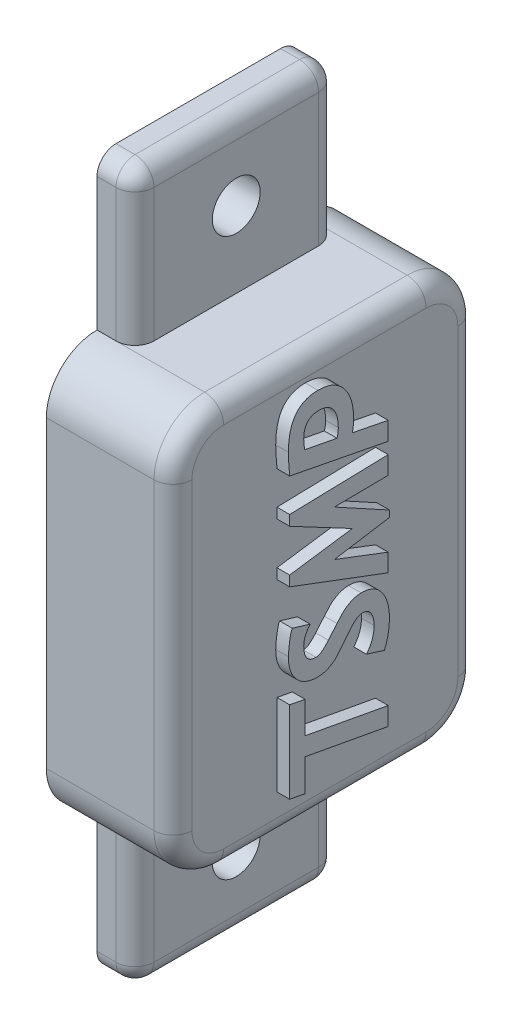
from build123d import *

# Parameters (mm, degrees)
BOSS_EXTRUDE1_DEPTH      = 6.35
SHELL1_T                 = -1.27
SKETCH2_W                = 3.81
SKETCH2_H                = 20.32
BOSS_EXTRUDE2_DEPTH      = 15.24
M4_CLEARANCE_HOLE1_D     = 4.8
M4_CLEARANCE_HOLE1_DEPTH = 3.81
BOSS_EXTRUDE3_DEPTH      = 1.27
FILLET1_R                = 1.905


with BuildPart() as part:
    # Sketch1 → Boss-Extrude1 (new body, symmetric)
    with BuildSketch(Plane(origin=(0, 0, 0), x_dir=(0, 0, -1), z_dir=(1, 0, 0))):
        with BuildLine():
            Line((10.16, 20.32), (-10.16, 20.32))
            ThreePointArc((-10.16, 20.32), (-13.752102448, 18.832102448), (-15.24, 15.24))
            Line((-15.24, 15.24), (-15.24, -15.24))
            ThreePointArc((-15.24, -15.24), (-13.752102448, -18.832102448), (-10.16, -20.32))
            Line((-10.16, -20.32), (10.16, -20.32))
            ThreePointArc((10.16, -20.32), (13.752102448, -18.832102448), (15.24, -15.24))
            Line((15.24, -15.24), (15.24, 15.24))
            ThreePointArc((15.24, 15.24), (13.752102448, 18.832102448), (10.16, 20.32))
        make_face()
    extrude(amount=BOSS_EXTRUDE1_DEPTH, both=True)

    # Shell1
    shell1_openings = [part.faces().sort_by_distance(p)[0] for p in [
        (-6.35, 0, 0),
    ]]
    offset(amount=SHELL1_T, openings=shell1_openings, kind=Kind.INTERSECTION)

    # Sketch2 → Boss-Extrude2 (add)
    with BuildSketch(Plane.XZ.offset(20.32)):
        with Locations((-4.445, 0)):
            Rectangle(SKETCH2_W, SKETCH2_H)
    boss_extrude2 = extrude(amount=BOSS_EXTRUDE2_DEPTH)

    # M4 Clearance Hole1
    with Locations(Plane(origin=(-2.54, 0, 0), x_dir=(0, 0, -1), z_dir=(1, 0, 0))):
        with Locations((0, -27.94)):
            m4_clearance_hole1 = Hole(M4_CLEARANCE_HOLE1_D / 2, depth=M4_CLEARANCE_HOLE1_DEPTH)

    # Mirror1: Boss-Extrude2, M4 Clearance Hole1 across plane
    add(boss_extrude2.mirror(Plane.ZX))
    add(m4_clearance_hole1.mirror(Plane.ZX), mode=Mode.SUBTRACT)

    # Sketch8 → Boss-Extrude3 (add)
    with BuildSketch(Plane(origin=(6.35, 0, 0), x_dir=(0, 0, -1), z_dir=(1, 0, 0))):
        Polygon((-3.263618594, -8.225283619), (-3.263618594, -11.400271175), (5.08, -12.938625853), (5.08, -14.761786743), (-3.263618594, -13.221426387), (-3.263618594, -16.430510462), (-4.80397895, -16.14570425), (-4.80397895, -7.934460374), align=None)
        with BuildLine():
            add(Edge.make_bspline(
                [(-2.750165142, -1.95352993), (-2.80125104, -2.017677687), (-2.900986105, -2.142913435), (-3.031358515, -2.338261172), (-3.143006892, -2.533506612), (-3.233848259, -2.730752845), (-3.303890362, -2.928950045), (-3.354883675, -3.127492488), (-3.386187219, -3.327085952), (-3.39005041, -3.461020967), (-3.391981957, -3.527986804)],
                knots=[0, 0, 0, 0, 0.000245923, 0.000480115, 0.000703764, 0.000920052, 0.001130657, 0.001333509, 0.001534337, 0.001735155, 0.001735155, 0.001735155, 0.001735155], degree=3))
            add(Edge.make_bspline(
                [(-3.391981957, -3.527986804), (-3.3916293, -3.592878461), (-3.390944594, -3.718869665), (-3.373803164, -3.900934818), (-3.349810891, -4.070269357), (-3.319309536, -4.227879526), (-3.274070717, -4.37216332), (-3.222660858, -4.505639649), (-3.160855456, -4.626504675), (-3.087780872, -4.734006273), (-3.005813293, -4.828538209), (-2.913292027, -4.910514792), (-2.811858608, -4.980505864), (-2.699620978, -5.036969834), (-2.579328244, -5.08160209), (-2.448326395, -5.110523489), (-2.308949539, -5.131974126), (-2.212064918, -5.133667989), (-2.162501621, -5.134534519)],
                knots=[0, 0, 0, 0, 0.000194592, 0.000377813, 0.000548, 0.0007077, 0.0008587, 0.001000976, 0.00113643, 0.001264934, 0.001390028, 0.001510786, 0.001634846, 0.001758631, 0.001886806, 0.002018648, 0.002160471, 0.002309013, 0.002309013, 0.002309013, 0.002309013], degree=3))
            add(Edge.make_bspline(
                [(-2.162501621, -5.134534519), (-2.117436706, -5.131528884), (-2.024312956, -5.125317932), (-1.88280649, -5.081657896), (-1.736607088, -5.012195006), (-1.58315581, -4.916720556), (-1.425322977, -4.792915034), (-1.260334105, -4.64296288), (-1.088306144, -4.467290665), (-0.976998716, -4.336338494), (-0.918981542, -4.268081819)],
                knots=[0, 0, 0, 0, 0.000135112, 0.0002792, 0.000440716, 0.000619941, 0.000820127, 0.001041662, 0.00128845, 0.001557128, 0.001557128, 0.001557128, 0.001557128], degree=3))
            Line((-0.918981542, -4.268081819), (-0.054534519, -3.24518627))
            add(Edge.make_bspline(
                [(-0.054534519, -3.24518627), (0.007627221, -3.172308071), (0.122069723, -3.038136097), (0.279085299, -2.854357732), (0.413087131, -2.710696977), (0.521828813, -2.591380531), (0.63069573, -2.492559642), (0.748004134, -2.396766845), (0.884686606, -2.300051516), (1.086844297, -2.168430987), (1.353379879, -2.021290492), (1.687687303, -1.892462062), (2.026955675, -1.812767653), (2.256261402, -1.80229614), (2.370329635, -1.797087082)],
                knots=[0, 0, 0, 0, 0.000287379, 0.000529078, 0.000724978, 0.000876789, 0.001013057, 0.001165607, 0.001330914, 0.001515054, 0.0018893, 0.002241666, 0.002587132, 0.002929093, 0.002929093, 0.002929093, 0.002929093], degree=3))
            add(Edge.make_bspline(
                [(2.370329635, -1.797087082), (2.478836795, -1.799964201), (2.69094982, -1.805588481), (2.998846952, -1.855418306), (3.28972316, -1.932701452), (3.560883137, -2.045837123), (3.814753113, -2.189996227), (4.050631053, -2.364961838), (4.266669818, -2.574066327), (4.461480384, -2.813118763), (4.638288906, -3.075229865), (4.789881922, -3.359679973), (4.921682336, -3.660747475), (5.025154706, -3.982411783), (5.10687616, -4.321730324), (5.16790922, -4.680057446), (5.201067337, -5.057685433), (5.205896626, -5.315653535), (5.208363363, -5.447420217)],
                knots=[0, 0, 0, 0, 0.000325316, 0.000635937, 0.000933224, 0.001226362, 0.001514691, 0.001807122, 0.002105004, 0.002414197, 0.002730719, 0.003051985, 0.003379869, 0.003715393, 0.004064185, 0.00442623, 0.004804836, 0.005200138, 0.005200138, 0.005200138, 0.005200138], degree=3))
            add(Edge.make_bspline(
                [(5.208363363, -5.447420217), (5.206855206, -5.557777808), (5.203862691, -5.776751431), (5.178842454, -6.102740636), (5.139239727, -6.423452807), (5.082416071, -6.739992962), (5.010856006, -7.052140548), (4.921802425, -7.359874574), (4.818672032, -7.663007591), (4.736163682, -7.860022177), (4.694909911, -7.958528505)],
                knots=[0, 0, 0, 0, 0.000331034, 0.000656844, 0.00098025, 0.00130011, 0.001621219, 0.001940525, 0.002260837, 0.002581143, 0.002581143, 0.002581143, 0.002581143], degree=3))
            Line((4.694909911, -7.958528505), (2.897822829, -7.388916082))
            add(Edge.make_bspline(
                [(2.897822829, -7.388916082), (2.959364284, -7.312381552), (3.080897423, -7.161239828), (3.237818498, -6.91868989), (3.370486213, -6.66757251), (3.479726078, -6.407287772), (3.564256024, -6.137321737), (3.623924089, -5.858006554), (3.661279945, -5.570110201), (3.665746681, -5.37532925), (3.668003007, -5.276937625)],
                knots=[0, 0, 0, 0, 0.000294473, 0.00058153, 0.000865041, 0.001145528, 0.001427181, 0.001712389, 0.002001464, 0.002296544, 0.002296544, 0.002296544, 0.002296544], degree=3))
            add(Edge.make_bspline(
                [(3.668003007, -5.276937625), (3.663994722, -5.161083602), (3.656274846, -4.937951143), (3.601877118, -4.617508863), (3.501824564, -4.329519036), (3.389585851, -4.113482056), (3.282231782, -3.960506275), (3.191956208, -3.862792545), (3.095092781, -3.778818092), (2.988821213, -3.711558275), (2.874408538, -3.660154277), (2.752264675, -3.620636889), (2.621787845, -3.59925378), (2.532190601, -3.59588574), (2.486658932, -3.594174164)],
                knots=[0, 0, 0, 0, 0.000347561, 0.000669396, 0.000970682, 0.001258677, 0.001396705, 0.001530139, 0.001656751, 0.001780275, 0.00190593, 0.002032161, 0.002164383, 0.002301005, 0.002301005, 0.002301005, 0.002301005], degree=3))
            add(Edge.make_bspline(
                [(2.486658932, -3.594174164), (2.438951786, -3.597212088), (2.340631421, -3.603472991), (2.1925958, -3.645712179), (2.043176312, -3.716144538), (1.889639511, -3.811584745), (1.733068719, -3.935429567), (1.57348056, -4.087000052), (1.408564625, -4.263212942), (1.303746122, -4.394340407), (1.249155886, -4.462632541)],
                knots=[0, 0, 0, 0, 0.000143094, 0.000294904, 0.00045824, 0.000637465, 0.000836068, 0.001056007, 0.001297256, 0.001559456, 0.001559456, 0.001559456, 0.001559456], degree=3))
            Line((1.249155886, -4.462632541), (0.404765639, -5.527647318))
            add(Edge.make_bspline(
                [(0.404765639, -5.527647318), (0.344161042, -5.602718848), (0.233172899, -5.740200986), (0.078190288, -5.925533002), (-0.0489091, -6.072532992), (-0.157785231, -6.186597947), (-0.260952852, -6.281911519), (-0.375599357, -6.370811159), (-0.507280539, -6.461763927), (-0.702176664, -6.586646654), (-0.963589433, -6.722379395), (-1.291549182, -6.844902551), (-1.631844494, -6.917501274), (-1.861979507, -6.926889471), (-1.977979286, -6.931621601)],
                knots=[0, 0, 0, 0, 0.000289437, 0.00053006, 0.000724776, 0.000872299, 0.001002899, 0.001145739, 0.001307093, 0.001482919, 0.001839952, 0.002188323, 0.002530548, 0.002878364, 0.002878364, 0.002878364, 0.002878364], degree=3))
            add(Edge.make_bspline(
                [(-1.977979286, -6.931621601), (-2.088436006, -6.929053441), (-2.304834699, -6.92402209), (-2.62050583, -6.880880309), (-2.918727289, -6.81204172), (-3.198077668, -6.711302875), (-3.462534406, -6.589054057), (-3.70587649, -6.432018726), (-3.933410594, -6.250176307), (-4.14030324, -6.039987171), (-4.326720414, -5.807190911), (-4.489787292, -5.55609666), (-4.626674869, -5.28691941), (-4.739783954, -5.001105155), (-4.825105438, -4.697029016), (-4.887008478, -4.37639866), (-4.926313289, -4.039074292), (-4.930305531, -3.808223382), (-4.932342313, -3.690446686)],
                knots=[0, 0, 0, 0, 0.000331234, 0.00064893, 0.000953958, 0.001247672, 0.001538357, 0.001826016, 0.002114192, 0.002410605, 0.002708804, 0.003007549, 0.003307148, 0.003613301, 0.003928199, 0.004253107, 0.004592208, 0.004945413, 0.004945413, 0.004945413, 0.004945413], degree=3))
            add(Edge.make_bspline(
                [(-4.932342313, -3.690446686), (-4.930462207, -3.60483434), (-4.926447217, -3.422008045), (-4.902699038, -3.131017922), (-4.866182337, -2.806698164), (-4.818831787, -2.463228834), (-4.759311523, -2.132128916), (-4.696669399, -1.841035416), (-4.629643785, -1.605349605), (-4.572432677, -1.471089287), (-4.547252224, -1.411996993)],
                knots=[0, 0, 0, 0, 0.000256852, 0.000548511, 0.00087543, 0.001235945, 0.001588454, 0.001884317, 0.002129256, 0.002321811, 0.002321811, 0.002321811, 0.002321811], degree=3))
            Line((-4.547252224, -1.411996993), (-2.750165142, -1.95352993))
        make_face()
        Polygon((5.08, 7.059984964), (-0.311261245, 6.995803283), (5.208363363, 3.979264252), (5.208363363, 3.337447438), (-0.311261245, 2.438903897), (5.08, 0.385090089), (5.08, -1.411996993), (-4.80397895, 2.310540534), (-4.80397895, 3.337447438), (1.485825836, 4.235990978), (-4.80397895, 7.573438416), (-4.80397895, 8.60034532), (5.08, 8.857072046), align=None)
        with BuildLine():
            Line((1.485825836, 12.549524409), (5.08, 11.839514558))
            Line((5.08, 11.839514558), (5.08, 10.012342313))
            Line((5.08, 10.012342313), (-4.80397895, 11.937792757))
            add(Edge.make_bspline(
                [(-4.80397895, 11.937792757), (-4.814156449, 12.051434856), (-4.833847704, 12.271307686), (-4.860016651, 12.59088044), (-4.882078557, 12.889067657), (-4.900309123, 13.166519858), (-4.914485749, 13.423257287), (-4.924511389, 13.659275476), (-4.931022551, 13.874572005), (-4.931917059, 14.010990788), (-4.932342313, 14.075845022)],
                knots=[0, 0, 0, 0, 0.00034229, 0.000662257, 0.000961916, 0.001239287, 0.001496398, 0.00173328, 0.001947972, 0.002142533, 0.002142533, 0.002142533, 0.002142533], degree=3))
            add(Edge.make_bspline(
                [(-4.932342313, 14.075845022), (-4.929994019, 14.233018019), (-4.925441487, 14.537722257), (-4.89155068, 14.979844931), (-4.834371192, 15.392089824), (-4.752611172, 15.773582457), (-4.648650738, 16.124611989), (-4.522356955, 16.446063441), (-4.372807301, 16.7381611), (-4.197662971, 16.998753815), (-3.998688334, 17.228092416), (-3.777747093, 17.428874214), (-3.529803779, 17.595220741), (-3.262179375, 17.735411413), (-2.969855722, 17.841393104), (-2.655210366, 17.917798277), (-2.316805288, 17.96114947), (-2.083733047, 17.967570542), (-1.963939544, 17.970870818)],
                knots=[0, 0, 0, 0, 0.000471488, 0.000914052, 0.00132931, 0.00171916, 0.002083399, 0.002426423, 0.002753846, 0.003065921, 0.003365922, 0.003662742, 0.003958693, 0.004259211, 0.004566969, 0.004889004, 0.005228835, 0.005588209, 0.005588209, 0.005588209, 0.005588209], degree=3))
            add(Edge.make_bspline(
                [(-1.963939544, 17.970870818), (-1.828012188, 17.967787718), (-1.562952501, 17.961775643), (-1.177130868, 17.903782877), (-0.813470233, 17.811477848), (-0.470827565, 17.684602911), (-0.15298743, 17.514847555), (0.144163358, 17.311681133), (0.418059524, 17.069558943), (0.665037351, 16.791227647), (0.890743886, 16.488034969), (1.081961827, 16.156716338), (1.248142725, 15.806492065), (1.38221737, 15.433549866), (1.486747174, 15.038929234), (1.559108714, 14.622807642), (1.607848845, 14.185307146), (1.612041718, 13.886113427), (1.614189199, 13.732874162)],
                knots=[0, 0, 0, 0, 0.000407552, 0.000794731, 0.001167356, 0.001531683, 0.00188787, 0.00224559, 0.002609365, 0.002981471, 0.003360156, 0.003741298, 0.004127098, 0.004521733, 0.004928445, 0.005350201, 0.005787871, 0.006247385, 0.006247385, 0.006247385, 0.006247385], degree=3))
            add(Edge.make_bspline(
                [(1.614189199, 13.732874162), (1.612668604, 13.633207172), (1.609633206, 13.434252989), (1.584417121, 13.137025147), (1.545360043, 12.841560925), (1.505684214, 12.646936835), (1.485825836, 12.549524409)],
                knots=[0, 0, 0, 0, 0.000298954, 0.000596768, 0.000894319, 0.001192484, 0.001192484, 0.001192484, 0.001192484], degree=3))
        make_face()
        with BuildLine():
            Line((-3.285681047, 13.468124725), (-0.054534519, 12.844359008))
            add(Edge.make_bspline(
                [(-0.054534519, 12.844359008), (-0.034389061, 12.904147934), (0.008182138, 13.030493348), (0.045042439, 13.236945911), (0.070066075, 13.466159412), (0.072531969, 13.626489962), (0.073828844, 13.710811709)],
                knots=[0, 0, 0, 0, 0.000189045, 0.000399488, 0.000627404, 0.000880247, 0.000880247, 0.000880247, 0.000880247], degree=3))
            add(Edge.make_bspline(
                [(0.073828844, 13.710811709), (0.072049248, 13.802425308), (0.068562733, 13.981911076), (0.048426275, 14.243680523), (0.005595908, 14.490136473), (-0.043212252, 14.723412765), (-0.115963113, 14.941015423), (-0.19773167, 15.145815837), (-0.300310289, 15.334389308), (-0.415350356, 15.508461826), (-0.545197842, 15.665180046), (-0.689167391, 15.801471519), (-0.84690039, 15.916631203), (-1.017866417, 16.011429658), (-1.202840813, 16.08402228), (-1.40074977, 16.135698609), (-1.61249225, 16.169005793), (-1.758562062, 16.172162654), (-1.833570503, 16.173783736)],
                knots=[0, 0, 0, 0, 0.000274895, 0.000538563, 0.000786522, 0.001024953, 0.001252657, 0.001473901, 0.001685678, 0.001895394, 0.002099037, 0.002294834, 0.002488598, 0.002683407, 0.002879687, 0.003083043, 0.00329607, 0.00352093, 0.00352093, 0.00352093, 0.00352093], degree=3))
            add(Edge.make_bspline(
                [(-1.833570503, 16.173783736), (-1.896464905, 16.17283222), (-2.018587962, 16.170984647), (-2.195892267, 16.150898559), (-2.360690984, 16.116296397), (-2.515046517, 16.071710293), (-2.654406343, 16.008300871), (-2.784401337, 15.936080569), (-2.899772308, 15.846944023), (-3.006023366, 15.74695384), (-3.09542669, 15.630213154), (-3.178054972, 15.50368517), (-3.242153196, 15.360749146), (-3.297140382, 15.205827013), (-3.341340613, 15.038285162), (-3.370454454, 14.856219611), (-3.388863548, 14.661216875), (-3.39091994, 14.526498561), (-3.391981957, 14.456923756)],
                knots=[0, 0, 0, 0, 0.00018863, 0.000366265, 0.000534228, 0.000693487, 0.000847036, 0.000992568, 0.001138584, 0.001283271, 0.001428928, 0.001578603, 0.001735636, 0.001897401, 0.002071561, 0.002254562, 0.002449948, 0.002658625, 0.002658625, 0.002658625, 0.002658625], degree=3))
            add(Edge.make_bspline(
                [(-3.391981957, 14.456923756), (-3.390904793, 14.37933002), (-3.388700582, 14.220549198), (-3.367406535, 13.977538618), (-3.333416827, 13.72529466), (-3.301791366, 13.554916848), (-3.285681047, 13.468124725)],
                knots=[0, 0, 0, 0, 0.000232736, 0.000476251, 0.000731256, 0.000996043, 0.000996043, 0.000996043, 0.000996043], degree=3))
        make_face(mode=Mode.SUBTRACT)
    extrude(amount=BOSS_EXTRUDE3_DEPTH)

    # Fillet1
    fillet1_edges = [part.edges().sort_by_distance(p)[0] for p in [
        (6.35, 18.832102448, -13.752102448),
        (6.35, 20.32, 0),
        (6.35, 18.832102448, 13.752102448),
        (6.35, 0, 15.24),
        (6.35, -18.832102448, 13.752102448),
        (6.35, -20.32, 0),
        (-2.54, -27.94, -10.16),
        (-2.54, -27.94, 10.16),
        (-4.445, -35.56, -10.16),
        (-2.54, -35.56, 0),
        (-4.445, -35.56, 10.16),
        (6.35, -18.832102448, -13.752102448),
        (-4.445, 35.56, 10.16),
        (-2.54, 35.56, 0),
        (-2.54, 27.94, 10.16),
        (-4.445, 35.56, -10.16),
        (-2.54, 27.94, -10.16),
        (6.35, 0, -15.24),
    ]]
    fillet(fillet1_edges, radius=FILLET1_R)


solid = part.part
